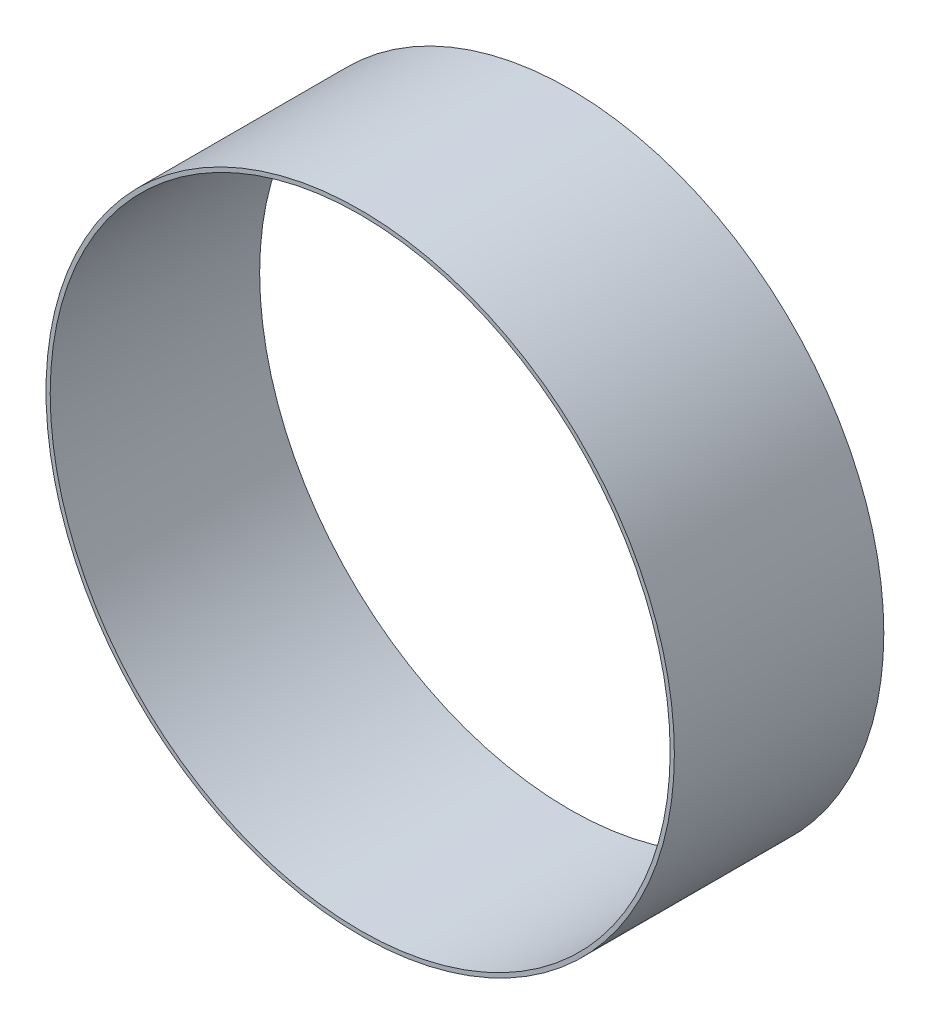
from build123d import *

# Parameters (mm, degrees)
SKETCH_1_R      = 150
SKETCH_1_R_2    = 148
EXTRUDE_1_DEPTH = 100


with BuildPart() as part:
    # 草图1 → 凸台-拉伸1 (new body)
    with BuildSketch(Plane.XY):
        Circle(SKETCH_1_R)
        Circle(SKETCH_1_R_2, mode=Mode.SUBTRACT)
    extrude(amount=EXTRUDE_1_DEPTH)


solid = part.part
